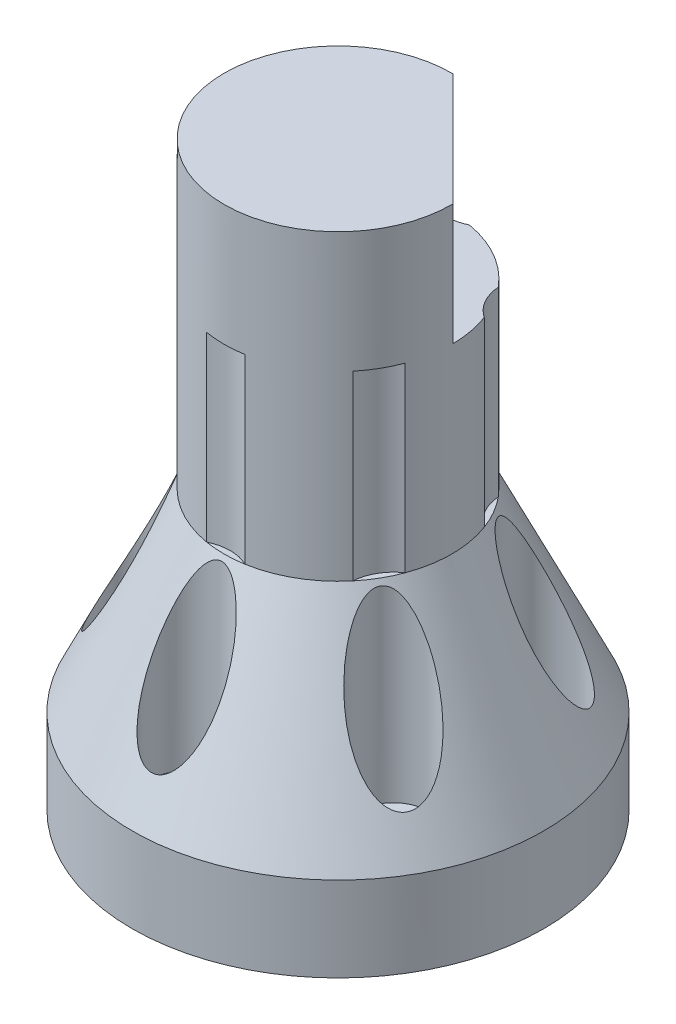
from build123d import *

# Parameters (mm, degrees)
SKETCH_25_R         = 17
SKETCH_25_R_2       = 1.65
EXTRUDE_1_DEPTH     = 7
EXTRUDE_2_DEPTH     = 15
SKETCH_28_R         = 17
SKETCH_33_R         = 9.4
SKETCH_30_R         = 2.15
CUT_EXTRUDE_1_DEPTH = 3
SKETCH_34_R         = 2.9
CUT_EXTRUDE_2_DEPTH = 32
EXTRUDE_3_DEPTH     = 10
SKETCH_36_R         = 9.5
SKETCH_36_R_2       = 9.4
CUT_EXTRUDE_3_DEPTH = 25


with BuildPart() as part:
    # 草图25 → 凸台-拉伸1 (new body)
    with BuildSketch(Plane(origin=(0, 0, 0), x_dir=(1, 0, 0), z_dir=(0, 1, 0))):
        Circle(SKETCH_25_R)
        with Locations((0, 12.5)):
            Circle(SKETCH_25_R_2, mode=Mode.SUBTRACT)
        with Locations((10.825317547, 6.25)):
            Circle(SKETCH_25_R_2, mode=Mode.SUBTRACT)
        with Locations((10.825317547, -6.25)):
            Circle(SKETCH_25_R_2, mode=Mode.SUBTRACT)
        with Locations((0, -12.5)):
            Circle(SKETCH_25_R_2, mode=Mode.SUBTRACT)
        with Locations((-10.825317547, -6.25)):
            Circle(SKETCH_25_R_2, mode=Mode.SUBTRACT)
        with Locations((-10.825317547, 6.25)):
            Circle(SKETCH_25_R_2, mode=Mode.SUBTRACT)
    extrude(amount=EXTRUDE_1_DEPTH)



with BuildPart() as body_2:
    # 草图26 → 凸台-拉伸2 (new body)
    with BuildSketch(Plane(origin=(0, 38, 0), x_dir=(1, 0, 0), z_dir=(0, 1, 0))):
        with BuildLine():
            ThreePointArc((1.727573281, -9.3416), (4.75, -8.227241336), (7.226276272, -6.166922348))
            ThreePointArc((7.226276272, -6.166922348), (7.707626094, -4.45), (8.953849552, -3.174677652))
            ThreePointArc((8.953849552, -3.174677652), (9.5, 0), (8.953849552, 3.174677652))
            ThreePointArc((8.953849552, 3.174677652), (7.707626094, 4.45), (7.226276272, 6.166922348))
            ThreePointArc((7.226276272, 6.166922348), (4.75, 8.227241336), (1.727573281, 9.3416))
            ThreePointArc((1.727573281, 9.3416), (0, 8.9), (-1.727573281, 9.3416))
            ThreePointArc((-1.727573281, 9.3416), (-4.75, 8.227241336), (-7.226276272, 6.166922348))
            ThreePointArc((-7.226276272, 6.166922348), (-7.707626094, 4.45), (-8.953849552, 3.174677652))
            ThreePointArc((-8.953849552, 3.174677652), (-9.5, 0), (-8.953849552, -3.174677652))
            ThreePointArc((-8.953849552, -3.174677652), (-7.707626094, -4.45), (-7.226276272, -6.166922348))
            ThreePointArc((-7.226276272, -6.166922348), (-4.75, -8.227241336), (-1.727573281, -9.3416))
            ThreePointArc((-1.727573281, -9.3416), (0, -8.9), (1.727573281, -9.3416))
        make_face()
    extrude(amount=-EXTRUDE_2_DEPTH)


with BuildPart() as part_1:
    add(part.part)

    add(body_2.part)  # 放样1 merges body 2
    # 草图28 → 放样1 section 0
    with BuildSketch(Plane(origin=(0, 7, 0), x_dir=(1, 0, 0), z_dir=(0, 1, 0))):
        Circle(SKETCH_28_R)
    # 草图33 → 放样1 section 1
    with BuildSketch(Plane.XZ.offset(-23)):
        Circle(SKETCH_33_R)
    loft()

    # 草图30 → 切除-拉伸1 (cut)
    with BuildSketch(Plane.XZ):
        with Locations((-10.2, 0)):
            Circle(SKETCH_30_R)
        with Locations((5.1, 8.833459119)):
            Circle(SKETCH_30_R)
        with Locations((5.1, -8.833459119)):
            Circle(SKETCH_30_R)
    extrude(amount=-CUT_EXTRUDE_1_DEPTH, mode=Mode.SUBTRACT)

    # 草图34 → 切除-拉伸2 (cut, through all)
    with BuildSketch(Plane.XZ.offset(-7)):
        with Locations((0, 12.5)):
            Circle(SKETCH_34_R)
        with Locations((10.825317547, 6.25)):
            Circle(SKETCH_34_R)
        with Locations((10.825317547, -6.25)):
            Circle(SKETCH_34_R)
        with Locations((0, -12.5)):
            Circle(SKETCH_34_R)
        with Locations((-10.825317547, -6.25)):
            Circle(SKETCH_34_R)
        with Locations((-10.825317547, 6.25)):
            Circle(SKETCH_34_R)
    extrude(amount=-CUT_EXTRUDE_2_DEPTH, mode=Mode.SUBTRACT)

    # 草图35 → 凸台-拉伸3 (add)
    with BuildSketch(Plane(origin=(0, 38, 0), x_dir=(1, 0, 0), z_dir=(0, 1, 0))):
        with BuildLine():
            Line((0, 9.5), (9.5, 0))
            ThreePointArc((9.5, 0), (-6.717514421, -6.717514421), (0, 9.5))
        make_face()
    extrude(amount=EXTRUDE_3_DEPTH)

    # 草图36 → 切除-拉伸3 (cut)
    with BuildSketch(Plane(origin=(0, 48, 0), x_dir=(1, 0, 0), z_dir=(0, 1, 0))):
        Circle(SKETCH_36_R)
        Circle(SKETCH_36_R_2, mode=Mode.SUBTRACT)
    extrude(amount=-CUT_EXTRUDE_3_DEPTH, mode=Mode.SUBTRACT)


solid = part_1.part
